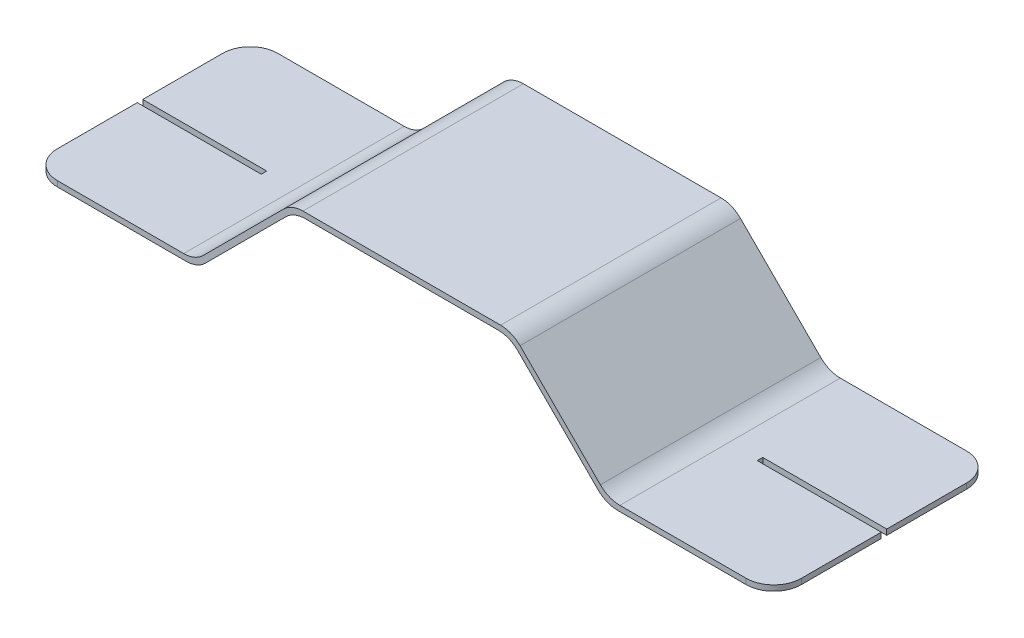
from build123d import *

# Parameters (mm, degrees)
BOSS_EXTRUDE1_DEPTH = 8
SKETCH2_R           = 1.190625
CUT_EXTRUDE1_DEPTH  = 15.990663761
FILLET1_R           = 1
FILLET2_R           = 1
SKETCH3_W           = 4.5
SKETCH3_H           = 0.2
CUT_EXTRUDE2_DEPTH  = 10


with BuildPart() as part:
    # Sketch1 → Boss-Extrude1 (new body)
    with BuildSketch(Plane.XY):
        Polygon((0, 0), (8, 0), (11.5, -3.5), (17.5, -3.5), (17.5, -3.7), (11.417157288, -3.7), (7.917157288, -0.2), (0.082842712, -0.2), (-3.417157288, -3.7), (-9.5, -3.7), (-9.5, -3.5), (-3.5, -3.5), align=None)
    extrude(amount=BOSS_EXTRUDE1_DEPTH)

    # Sketch2 → Cut-Extrude1 (cut, through all)
    with BuildSketch(Plane(origin=(0, 0, 0), x_dir=(0, 0, 1), z_dir=(-0.707106781, 0.707106781, 0))):
        with Locations((2.25, -2.5)):
            Circle(SKETCH2_R)
        with Locations((5.75, -2.5)):
            Circle(SKETCH2_R)
    extrude(amount=-CUT_EXTRUDE1_DEPTH, mode=Mode.SUBTRACT)

    # Fillet1
    fillet1_edges = [part.edges().sort_by_distance(p)[0] for p in [
        (0, 0, 4),
        (8, 0, 4),
        (11.5, -3.5, 4),
        (11.417157288, -3.7, 4),
        (7.917157288, -0.2, 4),
        (0.082842712, -0.2, 4),
        (-3.417157288, -3.7, 4),
        (-3.5, -3.5, 4),
    ]]
    fillet(fillet1_edges, radius=FILLET1_R)

    # Fillet2
    fillet2_edges = [part.edges().sort_by_distance(p)[0] for p in [
        (-9.5, -3.6, 8),
        (17.5, -3.6, 0),
        (-9.5, -3.6, 0),
        (17.5, -3.6, 8),
    ]]
    fillet(fillet2_edges, radius=FILLET2_R)

    # Sketch3 → Cut-Extrude2 (cut)
    with BuildSketch(Plane(origin=(0, -3.5, 0), x_dir=(1, 0, 0), z_dir=(0, 1, 0))):
        with Locations((-7.25, -4)):
            Rectangle(SKETCH3_W, SKETCH3_H)
    cut_extrude2 = extrude(amount=-CUT_EXTRUDE2_DEPTH, mode=Mode.SUBTRACT)

    # Mirror1: Cut-Extrude2 across plane
    add(cut_extrude2.mirror(Plane(origin=(4, 0, 0), x_dir=(0, 0, 1), z_dir=(1, 0, 0))), mode=Mode.SUBTRACT)


solid = part.part
